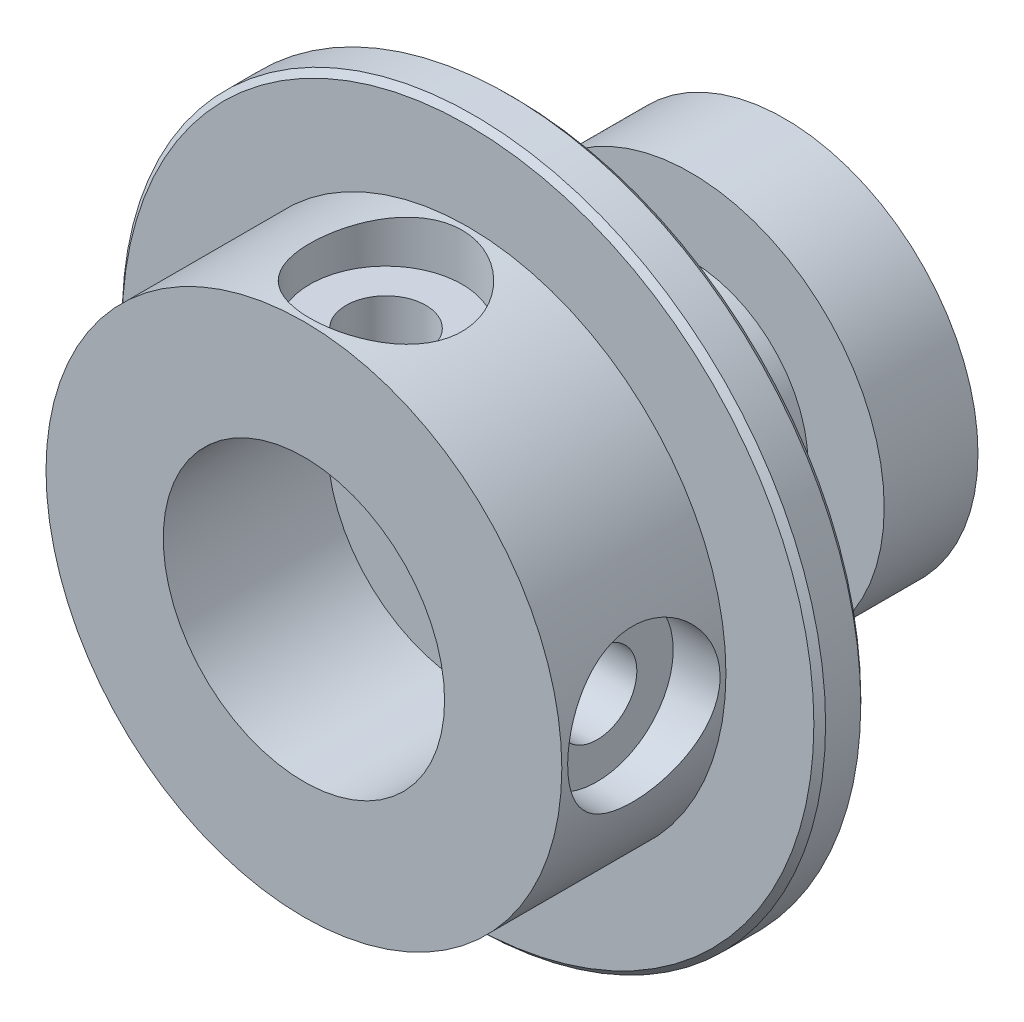
from build123d import *

# Parameters (mm, degrees)
CHAMFER1_SIZE                                       = 0.25
SKETCH2_R                                           = 2.5
CUT_EXTRUDE1_DEPTH                                  = 10
CBORE_FOR_M3_CHEESE_HEAD_SCREW1_D                   = 3.4
CBORE_FOR_M3_CHEESE_HEAD_SCREW1_DEPTH               = 10
CBORE_FOR_M3_CHEESE_HEAD_SCREW1_CBORE_D             = 6.5
CBORE_FOR_M3_CHEESE_HEAD_SCREW1_CBORE_DEPTH         = 2
CBORE_FOR_M3_CHEESE_HEAD_SCREW1_TIP                 = 1.021463052
CBORE_FOR_M3_CHEESE_HEAD_SCREW1_ON_FACE_D           = 3.4
CBORE_FOR_M3_CHEESE_HEAD_SCREW1_ON_FACE_DEPTH       = 10
CBORE_FOR_M3_CHEESE_HEAD_SCREW1_ON_FACE_CBORE_D     = 6.5
CBORE_FOR_M3_CHEESE_HEAD_SCREW1_ON_FACE_CBORE_DEPTH = 2
CBORE_FOR_M3_CHEESE_HEAD_SCREW1_ON_FACE_TIP         = 1.021463052


with BuildPart() as part:
    # Sketch1 → Revolve1 (revolve)
    with BuildSketch(Plane(origin=(0, 0, 0), x_dir=(1, 0, 0), z_dir=(0, 1, 0))):
        Polygon((6, 0), (0, 0), (0, 6.5), (8.25, 6.5), (8.25, 2), (15, 2), (15, 0), (11, 0), (11, -7), (6, -7), align=None)
    revolve(axis=Axis((0, 0, 17.872516556), (0, 0, -1)))

    # Chamfer1
    chamfer1_edges = [part.edges().sort_by_distance(p)[0] for p in [
        (-15, 0, 0),
        (-15, 0, -2),
    ]]
    chamfer(chamfer1_edges, length=CHAMFER1_SIZE)

    # Sketch2 → Cut-Extrude1 (cut)
    with BuildSketch(Plane(origin=(0, 0, -6.5), x_dir=(-1, 0, 0), z_dir=(0, 0, -1))):
        Circle(SKETCH2_R)
    extrude(amount=-CUT_EXTRUDE1_DEPTH, mode=Mode.SUBTRACT)

    # CBORE for M3 Cheese Head Screw1
    with Locations(Plane(origin=(0, 11, 3.5), x_dir=(1, 0, 0), z_dir=(0, 1, 0))):
        with Locations((0, 0)):
            CounterBoreHole(CBORE_FOR_M3_CHEESE_HEAD_SCREW1_D / 2, CBORE_FOR_M3_CHEESE_HEAD_SCREW1_CBORE_D / 2, CBORE_FOR_M3_CHEESE_HEAD_SCREW1_CBORE_DEPTH, depth=CBORE_FOR_M3_CHEESE_HEAD_SCREW1_DEPTH)
            with Locations((0, 0, -(CBORE_FOR_M3_CHEESE_HEAD_SCREW1_DEPTH + CBORE_FOR_M3_CHEESE_HEAD_SCREW1_TIP / 2))):  # 118° drill point
                Cone(0, CBORE_FOR_M3_CHEESE_HEAD_SCREW1_D / 2, CBORE_FOR_M3_CHEESE_HEAD_SCREW1_TIP, mode=Mode.SUBTRACT)

    # CBORE for M3 Cheese Head Screw1 on face
    with Locations(Plane(origin=(11, 0, 3.5), x_dir=(0, 0, 1), z_dir=(1, 0, 0))):
        with Locations((0, 0)):
            CounterBoreHole(CBORE_FOR_M3_CHEESE_HEAD_SCREW1_ON_FACE_D / 2, CBORE_FOR_M3_CHEESE_HEAD_SCREW1_ON_FACE_CBORE_D / 2, CBORE_FOR_M3_CHEESE_HEAD_SCREW1_ON_FACE_CBORE_DEPTH, depth=CBORE_FOR_M3_CHEESE_HEAD_SCREW1_ON_FACE_DEPTH)
            with Locations((0, 0, -(CBORE_FOR_M3_CHEESE_HEAD_SCREW1_ON_FACE_DEPTH + CBORE_FOR_M3_CHEESE_HEAD_SCREW1_ON_FACE_TIP / 2))):  # 118° drill point
                Cone(0, CBORE_FOR_M3_CHEESE_HEAD_SCREW1_ON_FACE_D / 2, CBORE_FOR_M3_CHEESE_HEAD_SCREW1_ON_FACE_TIP, mode=Mode.SUBTRACT)

    # Sketch5 → Revolve2 (revolve)
    with BuildSketch(Plane(origin=(0, 0, 0), x_dir=(1, 0, 0), z_dir=(0, 1, 0))):
        Polygon((2.5, 3.237551437), (2.5, 13.5), (8.25, 13.5), (8.25, 9.5), (5, 9.5), (5, 3.237551437), align=None)
    revolve(axis=Axis((0, 0, 0), (0, 0, -1)))


solid = part.part
